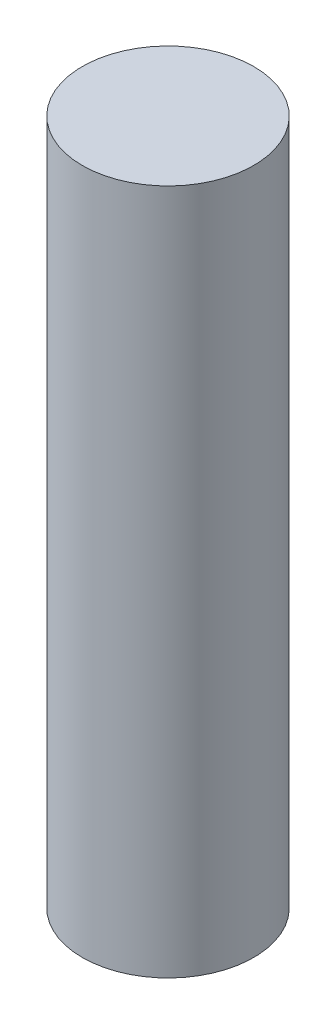
from build123d import *

# Parameters (mm, degrees)
SKETCH1_R           = 10
BOSS_EXTRUDE1_DEPTH = 80


with BuildPart() as part:
    # Sketch1 → Boss-Extrude1 (new body)
    with BuildSketch(Plane(origin=(0, 0, 0), x_dir=(1, 0, 0), z_dir=(0, 1, 0))):
        Circle(SKETCH1_R)
    extrude(amount=BOSS_EXTRUDE1_DEPTH)


solid = part.part
